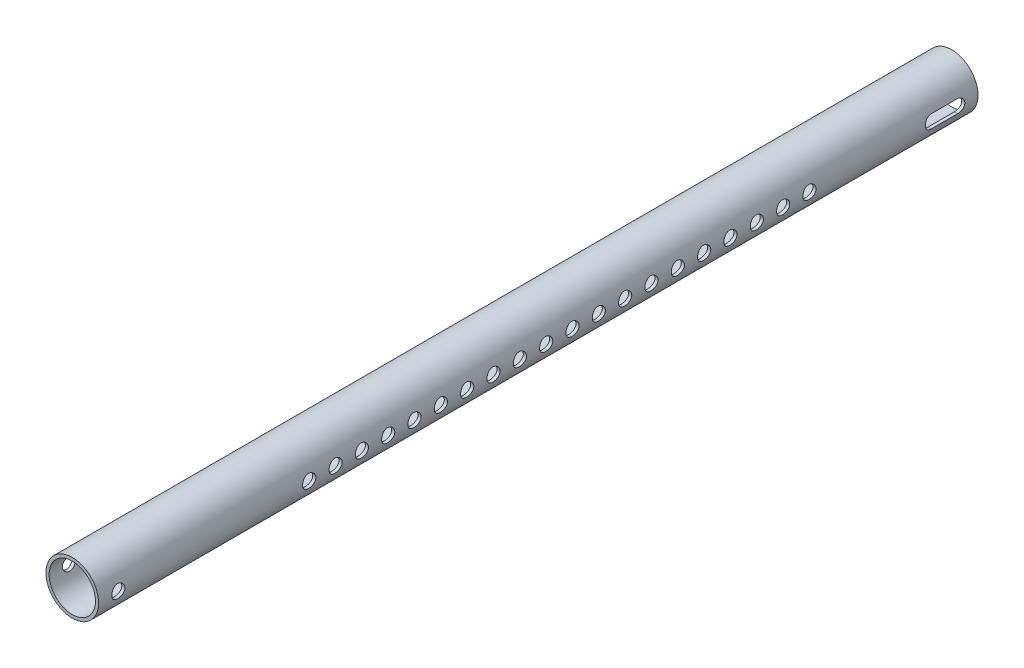
from build123d import *

# Parameters (mm, degrees)
SKETCH1_R                = 12.7
SKETCH1_R_2              = 11.176
BOSS_EXTRUDE1_DEPTH      = 212.09
BOSS_EXTRUDE1_DEPTH_BACK = 212.09
SKETCH2_R                = 3.175
CUT_EXTRUDE1_DEPTH       = 13.7
CUT_EXTRUDE1_DEPTH_BACK  = 13.7


with BuildPart() as part:
    # Sketch1 → Boss-Extrude1 (new body, two sides)
    with BuildSketch(Plane.XY) as boss_extrude1_sk:
        Circle(SKETCH1_R)
        Circle(SKETCH1_R_2, mode=Mode.SUBTRACT)
    extrude(amount=BOSS_EXTRUDE1_DEPTH)
    extrude(boss_extrude1_sk.sketch, amount=-BOSS_EXTRUDE1_DEPTH_BACK)

    # Sketch2 → Cut-Extrude1 (cut, two sides)
    with BuildSketch(Plane(origin=(0, 0, 0), x_dir=(0, 0, -1), z_dir=(1, 0, 0))) as cut_extrude1_sk:
        with Locations((-110.49, 0)):
            Circle(SKETCH2_R)
        with Locations((-97.79, 0)):
            Circle(SKETCH2_R)
        with Locations((-85.09, 0)):
            Circle(SKETCH2_R)
        with Locations((-72.39, 0)):
            Circle(SKETCH2_R)
        with Locations((-59.69, 0)):
            Circle(SKETCH2_R)
        with Locations((-46.99, 0)):
            Circle(SKETCH2_R)
        with Locations((-34.29, 0)):
            Circle(SKETCH2_R)
        with Locations((-21.59, 0)):
            Circle(SKETCH2_R)
        with Locations((-8.89, 0)):
            Circle(SKETCH2_R)
        with Locations((3.81, 0)):
            Circle(SKETCH2_R)
        with Locations((16.51, 0)):
            Circle(SKETCH2_R)
        with Locations((29.21, 0)):
            Circle(SKETCH2_R)
        with Locations((41.91, 0)):
            Circle(SKETCH2_R)
        with Locations((54.61, 0)):
            Circle(SKETCH2_R)
        with Locations((67.31, 0)):
            Circle(SKETCH2_R)
        with Locations((80.01, 0)):
            Circle(SKETCH2_R)
        with Locations((92.71, 0)):
            Circle(SKETCH2_R)
        with Locations((105.41, 0)):
            Circle(SKETCH2_R)
        with Locations((118.11, 0)):
            Circle(SKETCH2_R)
        with Locations((130.81, 0)):
            Circle(SKETCH2_R)
        with Locations((-202.565, 0)):
            Circle(SKETCH2_R)
        with BuildLine():
            Line((189.865, 3.175), (202.565, 3.175))
            ThreePointArc((202.565, 3.175), (205.74, 0), (202.565, -3.175))
            Line((202.565, -3.175), (189.865, -3.175))
            ThreePointArc((189.865, -3.175), (186.69, 0), (189.865, 3.175))
        make_face()
    extrude(amount=CUT_EXTRUDE1_DEPTH, mode=Mode.SUBTRACT)
    extrude(cut_extrude1_sk.sketch, amount=-CUT_EXTRUDE1_DEPTH_BACK, mode=Mode.SUBTRACT)


solid = part.part
